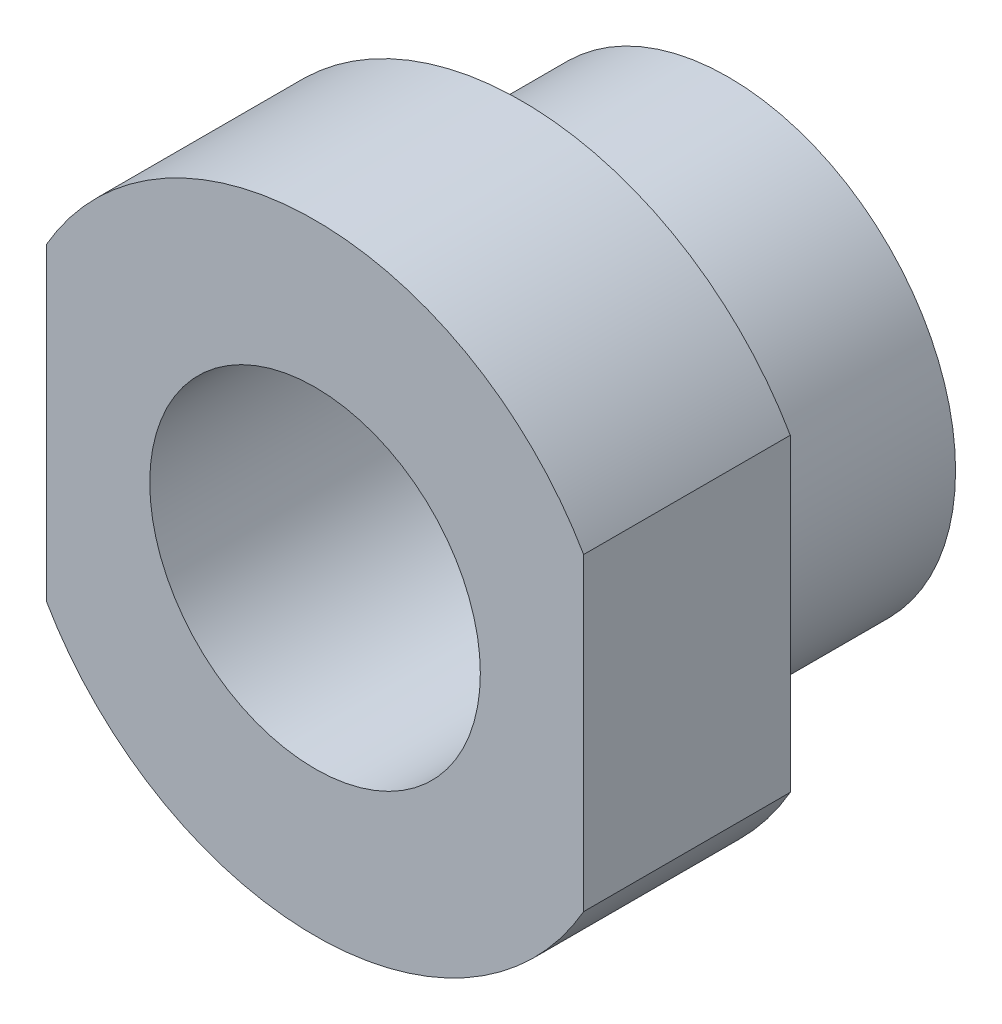
from build123d import *

# Parameters (mm, degrees)
SKETCH1_R           = 4
BOSS_EXTRUDE1_DEPTH = 5
SKETCH2_R           = 5.5
SKETCH2_R_2         = 4
BOSS_EXTRUDE2_DEPTH = 5


with BuildPart() as part:
    # Sketch1 → Boss-Extrude1 (new body)
    with BuildSketch(Plane.XY):
        with BuildLine():
            Line((-6.5, 3.741657387), (-6.5, -3.741657387))
            ThreePointArc((-6.5, -3.741657387), (0, -7.5), (6.5, -3.741657387))
            Line((6.5, -3.741657387), (6.5, 3.741657387))
            ThreePointArc((6.5, 3.741657387), (0, 7.5), (-6.5, 3.741657387))
        make_face()
        Circle(SKETCH1_R, mode=Mode.SUBTRACT)
    extrude(amount=BOSS_EXTRUDE1_DEPTH)

    # Sketch2 → Boss-Extrude2 (add)
    with BuildSketch(Plane(origin=(0, 0, 0), x_dir=(-1, 0, 0), z_dir=(0, 0, -1))):
        Circle(SKETCH2_R)
        Circle(SKETCH2_R_2, mode=Mode.SUBTRACT)
    extrude(amount=BOSS_EXTRUDE2_DEPTH)


solid = part.part
